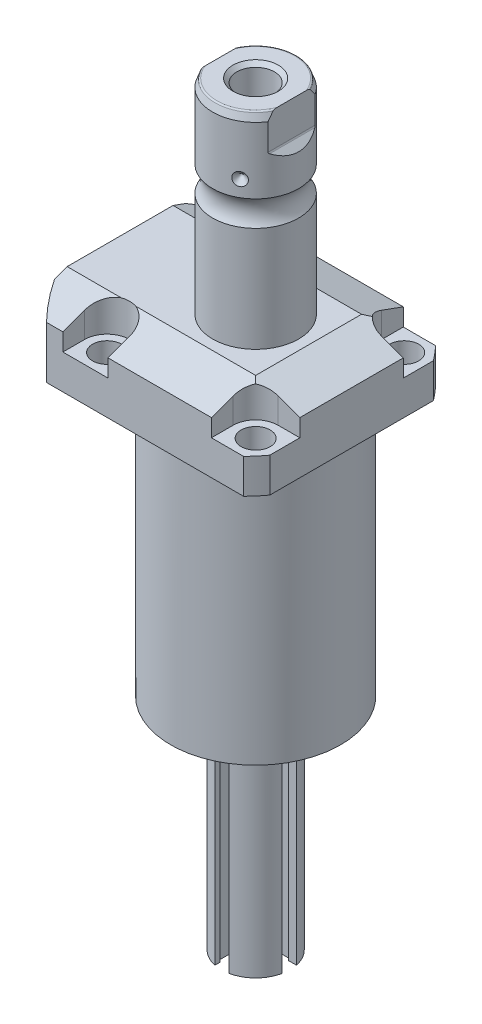
from build123d import *

# Parameters (mm, degrees)
SKETCH1_W                = 70.866
SKETCH1_H                = 85.496
EXTRUDE1_DEPTH           = 122.047
SKETCH2_OUTSIDE_W        = 120.498
SKETCH2_OUTSIDE_H        = 105.868
SKETCH2_OUTSIDE_R        = 50.8
CUT_EXTRUDE1_DEPTH       = 123.047
SKETCH3_W                = 45.1992
SKETCH3_H                = 97.028
FILLET1_R                = 0.381
CUT_EXTRUDE2_DEPTH       = 12.243
CUT_EXTRUDE9_START       = -51.063
CUT_EXTRUDE9_DEPTH       = 87.496
CUT_EXTRUDE7_DEPTH       = 36.433
CUT_EXTRUDE7_DEPTH_BACK  = 36.433
SKETCH10_R               = 1.1811
SKETCH17_W               = 5.3594
SKETCH17_H               = 12.776
HOLE1_AT_2_COUNT         = 2
HOLE1_AT_2_PITCH         = 54.864
HOLE1_AT_3_COUNT         = 2
HOLE1_AT_3_PITCH         = 77.589412886
HOLE1_AT_4_COUNT         = 2
HOLE1_AT_4_PITCH         = 54.864
CHAMFER1_SIZE            = 0.635
FILLET2_R                = 0.635
CIRPATTERN1_COUNT        = 3
CUT_EXTRUDE10_DEPTH      = 36.433
CUT_EXTRUDE10_DEPTH_BACK = 36.433
CHAMFER2_SIZE            = 1.4351
SKETCH33_R               = 2.7051
BOSS_EXTRUDE1_DEPTH      = 2.9972
CIRPATTERN2_COUNT        = 3
CUT_EXTRUDE11_DEPTH      = 70.612
CIRPATTERN3_COUNT        = 4
SKETCH35_R               = 3.4925
CUT_EXTRUDE15_DEPTH      = 7.62
CIRPATTERN4_COUNT        = 4
CUT_EXTRUDE16_DEPTH      = 1.27
CIRPATTERN5_COUNT        = 3
SKETCH39_R               = 1.7272
CUT_EXTRUDE17_DEPTH      = 2.54
CIRPATTERN6_COUNT        = 12


with BuildPart() as part:
    # Sketch1 → Extrude1 (new body)
    with BuildSketch(Plane(origin=(0, 0, 0), x_dir=(0, 0, 1), z_dir=(0, -1, 0))):
        with Locations((0, 7.315)):
            Rectangle(SKETCH1_W, SKETCH1_H)
    extrude(amount=-EXTRUDE1_DEPTH)

    # Sketch2 outside → Cut-Extrude1 (cut, through all)
    with BuildSketch(Plane.XZ):
        with Locations((-7.315, 0)):
            Rectangle(SKETCH2_OUTSIDE_W, SKETCH2_OUTSIDE_H)
        with Locations((-5.4102, 0)):
            Circle(SKETCH2_OUTSIDE_R, mode=Mode.SUBTRACT)
    extrude(amount=-CUT_EXTRUDE1_DEPTH, mode=Mode.SUBTRACT)

    # Sketch3 → Cut-Revolve1 (revolve, cut)
    with BuildSketch(Plane(origin=(0, 0, 0), x_dir=(0, 0, -1), z_dir=(1, 0, 0))):
        with Locations((53.9941, 48.514)):
            Rectangle(SKETCH3_W, SKETCH3_H)
    revolve(axis=Axis((0, -93.345, 0), (0, 1, 0)), mode=Mode.SUBTRACT)

    # Fillet1
    fillet1_edges = [part.edges().sort_by_distance(p)[0] for p in [
        (0, 97.028, 31.3945),
    ]]
    fillet(fillet1_edges, radius=FILLET1_R)

    # Sketch4 → Cut-Extrude2 (cut)
    with BuildSketch(Plane(origin=(0, 122.047, 0), x_dir=(-1, 0, 0), z_dir=(0, 1, 0))):
        with BuildLine():
            Line((-19.1008, -35.433), (-19.1008, -27.432))
            ThreePointArc((-19.1008, -27.432), (-21.540951985, -21.540951985), (-27.432, -19.1008))
            Line((-27.432, -19.1008), (-35.433, -19.1008))
            Line((-35.433, -19.1008), (-35.433, -35.433))
            Line((-35.433, -35.433), (-19.1008, -35.433))
        make_face()
        with BuildLine():
            Line((35.7632, -35.433), (19.1008, -35.433))
            Line((19.1008, -35.433), (19.1008, -27.432))
            ThreePointArc((19.1008, -27.432), (27.432, -19.1008), (35.7632, -27.432))
            Line((35.7632, -27.432), (35.7632, -35.433))
        make_face()
        with BuildLine():
            Line((19.1008, 35.433), (19.1008, 27.432))
            ThreePointArc((19.1008, 27.432), (27.432, 19.1008), (35.7632, 27.432))
            Line((35.7632, 27.432), (35.7632, 35.433))
            Line((35.7632, 35.433), (19.1008, 35.433))
        make_face()
        with BuildLine():
            Line((-27.432, 19.1008), (-35.433, 19.1008))
            Line((-35.433, 19.1008), (-35.433, 35.433))
            Line((-35.433, 35.433), (-19.1008, 35.433))
            Line((-19.1008, 35.433), (-19.1008, 27.432))
            ThreePointArc((-19.1008, 27.432), (-21.540951985, 21.540951985), (-27.432, 19.1008))
        make_face()
    extrude(amount=-CUT_EXTRUDE2_DEPTH, mode=Mode.SUBTRACT)

    # Sketch5 → Cut-Extrude9 (cut)
    with BuildSketch(Plane(origin=(0, 0, 0), x_dir=(0, 0, -1), z_dir=(1, 0, 0)).offset(CUT_EXTRUDE9_START)):
        Polygon((-19.558, 122.047), (-35.433, 116.268972531), (-35.433, 122.047), align=None)
    cut_extrude9 = extrude(amount=CUT_EXTRUDE9_DEPTH, mode=Mode.SUBTRACT)

    # Mirror1: Cut-Extrude9 across plane
    add(cut_extrude9.mirror(Plane.XY), mode=Mode.SUBTRACT)

    # Sketch9 → Cut-Extrude7 (cut, two sides)
    with BuildSketch(Plane.XY) as cut_extrude7_sk:
        Polygon((19.558, 122.047), (35.433, 116.268972531), (35.433, 122.047), align=None)
    extrude(amount=CUT_EXTRUDE7_DEPTH, mode=Mode.SUBTRACT)
    extrude(cut_extrude7_sk.sketch, amount=-CUT_EXTRUDE7_DEPTH_BACK, mode=Mode.SUBTRACT)

    # Sketch20 → Cut-Revolve4 (revolve, cut)
    with BuildSketch(Plane(origin=(-35.0774, 88.9, -18.1102), x_dir=(0, 1, 0), z_dir=(1, 0, 0)), mode=Mode.PRIVATE) as cut_revolve4_sk:
        Polygon((8.128, 38.3413), (9.5758, 38.3413), (9.5758, 35.8902), (10.5918, 35.8902), (10.5918, 33.8836), (21.5646, 33.8836), (21.5646, 32.639), (8.128, 32.639), align=None)
    cut_revolve4 = revolve(cut_revolve4_sk.sketch.rotate(Axis((-35.0774, 81.620304954, 14.5288), (0, 1, 0)), 180), axis=Axis((-35.0774, 81.620304954, 14.5288), (0, 1, 0)), mode=Mode.SUBTRACT)  # turned: the seam where the file's is

    # Mirror10: Cut-Revolve4 across plane
    add(cut_revolve4.mirror(Plane.XY), mode=Mode.SUBTRACT)

    # Sketch15 → Revolve3 (revolve)
    with BuildSketch(Plane(origin=(0, 0, 0), x_dir=(0, 0, -1), z_dir=(1, 0, 0)), mode=Mode.PRIVATE) as revolve3_sk:
        with BuildLine():
            Line((0, 122.047), (15.875, 122.047))
            Line((15.875, 122.047), (15.875, 160.74810643))
            ThreePointArc((15.875, 160.74810643), (14.3256, 165.4552), (15.875, 170.16229357))
            Line((15.875, 170.16229357), (15.875, 194.64019416))
            Line((15.875, 194.64019416), (14.81184082, 197.5612))
            Line((14.81184082, 197.5612), (0, 197.5612))
            Line((0, 197.5612), (0, 122.047))
        make_face()
    revolve(revolve3_sk.sketch.rotate(Axis((0, 250.290824608, 0), (0, -1, 0)), 180), axis=Axis((0, 250.290824608, 0), (0, -1, 0)))  # turned: the seam where the file's is

    # Sketch17 → Hole1 (revolve, cut)
    with BuildSketch(Plane(origin=(27.432, 109.804, -27.432), x_dir=(0, 0, 1), z_dir=(1, 0, 0))):
        with Locations((2.6797, 6.388)):
            Rectangle(SKETCH17_W, SKETCH17_H)
    hole1 = revolve(axis=Axis((27.432, -0.196, -27.432), (0, 1, 0)), mode=Mode.SUBTRACT)

    # Hole1 at 2: Hole1 ×2
    with Locations(*[(0, 0, i * HOLE1_AT_2_PITCH) for i in range(1, HOLE1_AT_2_COUNT)]):
        add(hole1, mode=Mode.SUBTRACT)

    # Hole1 at 3: Hole1 ×2
    with Locations(*[Vector(-0.707106781, 0, 0.707106781) * (i * HOLE1_AT_3_PITCH) for i in range(1, HOLE1_AT_3_COUNT)]):
        add(hole1, mode=Mode.SUBTRACT)

    # Hole1 at 4: Hole1 ×2
    with Locations(*[(-i * HOLE1_AT_4_PITCH, 0, 0) for i in range(1, HOLE1_AT_4_COUNT)]):
        add(hole1, mode=Mode.SUBTRACT)

    # Chamfer1
    chamfer1_edges = [part.edges().sort_by_distance(p)[0] for p in [
        (-35.0774, 99.4918, 15.7734),
        (-35.0774, 99.4918, -15.7734),
    ]]
    chamfer(chamfer1_edges, length=CHAMFER1_SIZE)

    # Sketch21 → Cut-Revolve5 (revolve, cut)
    with BuildSketch(Plane.XZ.offset(-109.5248)):
        Polygon((-50.063, -1.9304), (-49.809, -1.9304), (-49.809, -6.7564), (-47.2563, -7.440393904), (-46.695693904, -8.001), (-30.759, -8.001), (-30.759, -12.9794), (-50.063, -12.9794), align=None)
    cut_revolve5 = revolve(axis=Axis((-57.549532301, 109.5248, -12.9794), (1, 0, 0)), mode=Mode.SUBTRACT)

    # Mirror13: Cut-Revolve5 across plane
    add(cut_revolve5.mirror(Plane.XY), mode=Mode.SUBTRACT)

    # Fillet2
    fillet2_edges = [part.edges().sort_by_distance(p)[0] for p in [
        (0, 197.5612, -14.81184082),
    ]]
    fillet(fillet2_edges, radius=FILLET2_R)

    # Sketch26 → Cut-Revolve7 (revolve, cut)
    with BuildSketch(Plane.XY, mode=Mode.PRIVATE) as cut_revolve7_sk:
        Polygon((-15.875, 178.5362), (-13.462, 176.1232), (-15.875, 176.1232), align=None)
    cut_revolve7 = revolve(cut_revolve7_sk.sketch.rotate(Axis((-39.772000707, 176.1232, 0), (1, 0, 0)), 90), axis=Axis((-39.772000707, 176.1232, 0), (1, 0, 0)), mode=Mode.SUBTRACT)  # turned: the seam where the file's is

    # CirPattern1: Cut-Revolve7 ×3 about axis
    cirpattern1_axis = Axis((0, 250.290824608, 0), (0, 1, 0))
    for i in range(1, CIRPATTERN1_COUNT):
        add(cut_revolve7.rotate(cirpattern1_axis, i * 360 / CIRPATTERN1_COUNT), mode=Mode.SUBTRACT)

    # Sketch27 → Hole2 (revolve, cut)
    with BuildSketch(Plane(origin=(0, 197.5612, 0), x_dir=(0, 0, 1), z_dir=(1, 0, 0))):
        Polygon((0, 0), (0, 28.812118634), (6.9469, 24.638), (6.9469, 0), align=None)
    revolve(axis=Axis((0, 201.805399587, 0), (0, -1, 0)), mode=Mode.SUBTRACT)

    # Sketch29 → Cut-Extrude10 (cut, two sides)
    with BuildSketch(Plane.XY) as cut_extrude10_sk:
        with BuildLine():
            Line((13.284, 197.5612), (13.284, 184.8612))
            ThreePointArc((13.284, 184.8612), (13.342003912, 184.569594643), (13.507185078, 184.322383558))
            Line((13.507185078, 184.322383558), (16.332, 181.497568636))
            Line((16.332, 181.497568636), (16.332, 197.5612))
            Line((16.332, 197.5612), (13.284, 197.5612))
        make_face()
        with BuildLine():
            Line((-16.332, 197.5612), (-13.284, 197.5612))
            Line((-13.284, 197.5612), (-13.284, 184.8612))
            ThreePointArc((-13.284, 184.8612), (-13.342003912, 184.569594643), (-13.507185078, 184.322383558))
            Line((-13.507185078, 184.322383558), (-16.332, 181.497568636))
            Line((-16.332, 181.497568636), (-16.332, 197.5612))
        make_face()
    extrude(amount=CUT_EXTRUDE10_DEPTH, mode=Mode.SUBTRACT)
    extrude(cut_extrude10_sk.sketch, amount=-CUT_EXTRUDE10_DEPTH_BACK, mode=Mode.SUBTRACT)

    # Chamfer2
    chamfer2_edges = [part.edges().sort_by_distance(p)[0] for p in [
        (0, 197.5612, -6.9469),
    ]]
    chamfer(chamfer2_edges, length=CHAMFER2_SIZE)

    # Sketch30 → Revolve5 (revolve)
    with BuildSketch(Plane.XY, mode=Mode.PRIVATE) as revolve5_sk:
        Polygon((0, 0), (22.225, 0), (22.225, -2.54), (12.7, -2.54), (12.7, -81.28), (0, -81.28), align=None)
    revolve(revolve5_sk.sketch.rotate(Axis((0, 75.404549087, 0), (0, -1, 0)), 90), axis=Axis((0, 75.404549087, 0), (0, -1, 0)))  # turned: the seam where the file's is

    # Sketch33 → Boss-Extrude1 (add)
    with BuildSketch(Plane.XZ.offset(2.54)):
        with Locations(Location((19.431, 0, 0), (0, 0, 90))):  # turned: the seam where the file's is
            Circle(SKETCH33_R)
    boss_extrude1 = extrude(amount=BOSS_EXTRUDE1_DEPTH)

    # CirPattern2: Boss-Extrude1 ×3 about axis
    cirpattern2_axis = Axis((0, 0, 0), (0, 1, 0))
    for i in range(1, CIRPATTERN2_COUNT):
        add(boss_extrude1.rotate(cirpattern2_axis, i * 360 / CIRPATTERN2_COUNT))

    # Sketch34 → Cut-Extrude11 (cut)
    with BuildSketch(Plane.XZ.offset(81.28)):
        Polygon((13.335, -2.6416), (9.525, -2.6416), (9.525, -3.4925), (6.223, -3.4925), (6.223, 3.4925), (10.546286756, 3.4925), (10.546286756, 2.6416), (13.335, 2.6416), align=None)
    cut_extrude11 = extrude(amount=-CUT_EXTRUDE11_DEPTH, mode=Mode.SUBTRACT)

    # CirPattern3: Cut-Extrude11 ×4 about axis
    cirpattern3_axis = Axis((0, 0, 0), (0, 1, 0))
    for i in range(1, CIRPATTERN3_COUNT):
        add(cut_extrude11.rotate(cirpattern3_axis, i * 360 / CIRPATTERN3_COUNT), mode=Mode.SUBTRACT)

    # Sketch35 → Cut-Extrude15 (cut)
    with BuildSketch(Plane.XY.offset(6.223)):
        with Locations((0, -10.668)):
            Circle(SKETCH35_R)
    cut_extrude15 = extrude(amount=CUT_EXTRUDE15_DEPTH, mode=Mode.SUBTRACT)

    # CirPattern4: Cut-Extrude15 ×4 about axis
    cirpattern4_axis = Axis((0, 75.404549087, 0), (0, 1, 0))
    for i in range(1, CIRPATTERN4_COUNT):
        add(cut_extrude15.rotate(cirpattern4_axis, i * 360 / CIRPATTERN4_COUNT), mode=Mode.SUBTRACT)

    # Sketch37 → Cut-Extrude16 (cut)
    with BuildSketch(Plane.XZ.offset(5.5372)):
        Polygon((19.431, 1.2446), (20.14728, 1.2446), (20.865850145, 0), (20.14728, -1.2446), (18.71168029, -1.2446), (17.993110145, 0), (18.71168029, 1.2446), align=None)
    cut_extrude16 = extrude(amount=-CUT_EXTRUDE16_DEPTH, mode=Mode.SUBTRACT)

    # CirPattern5: Cut-Extrude16 ×3 about axis
    cirpattern5_axis = Axis((0, 0, 0), (0, 1, 0))
    for i in range(1, CIRPATTERN5_COUNT):
        add(cut_extrude16.rotate(cirpattern5_axis, i * 360 / CIRPATTERN5_COUNT), mode=Mode.SUBTRACT)

    # Sketch39 → Cut-Extrude17 (cut)
    with BuildSketch(Plane.XZ.offset(2.54)):
        with Locations(Location((19.431, 0, 0), (0, 0, 270))):  # turned: the seam where the file's is
            Circle(SKETCH39_R)
    cut_extrude17 = extrude(amount=-CUT_EXTRUDE17_DEPTH, mode=Mode.SUBTRACT)

    # CirPattern6: Cut-Extrude17 ×12 about axis
    cirpattern6_axis = Axis((0, 0, 0), (0, 1, 0))
    for i in range(1, CIRPATTERN6_COUNT):
        add(cut_extrude17.rotate(cirpattern6_axis, i * 360 / CIRPATTERN6_COUNT), mode=Mode.SUBTRACT)


with BuildPart() as body_2:
    # Sketch10 → Revolve4 (revolve)
    with BuildSketch(Plane(origin=(-35.0774, 88.9, -18.1102), x_dir=(0, 1, 0), z_dir=(1, 0, 0))):
        with Locations((8.3947, 8.1026)):
            Circle(SKETCH10_R)
    revolve(axis=Axis((-35.0774, 87.86749, -14.5288), (0, 1, 0)))


with BuildPart() as body_3:
    # Mirror12: mirrored copy
    add(body_2.part.mirror(Plane.XY))


solid = Compound([part.part, body_2.part, body_3.part])
